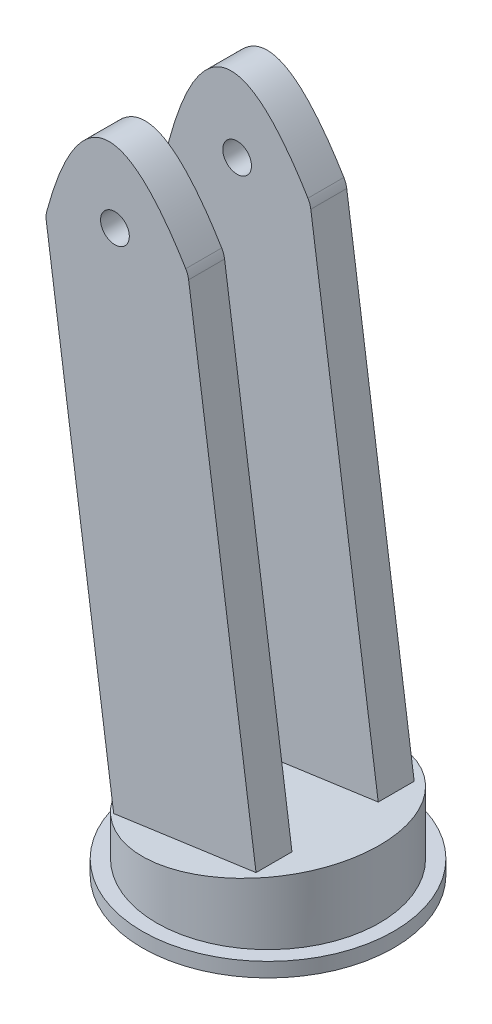
from build123d import *

# Parameters (mm, degrees)
CROQUIS2_R              = 17.5
SALIENTE_EXTRUIR1_DEPTH = 2
CROQUIS3_R              = 15.5
SALIENTE_EXTRUIR2_DEPTH = 10
CROQUIS6_W              = 20
CROQUIS6_H              = 5
SALIENTE_EXTRUIR4_DEPTH = 80
CROQUIS7_R              = 2
CORTAR_EXTRUIR4_DEPTH   = 97.577783797
REDONDEO1_R             = 3


with BuildPart() as part:
    # Croquis2 → Saliente-Extruir1 (new body)
    with BuildSketch(Plane(origin=(0, 0, 0), x_dir=(1, 0, 0), z_dir=(0, 1, 0))):
        with Locations(Location((0, 0, 0), (0, 0, 270))):
            Circle(CROQUIS2_R)
    extrude(amount=SALIENTE_EXTRUIR1_DEPTH)

    # Croquis3 → Saliente-Extruir2 (add)
    with BuildSketch(Plane(origin=(0, 2, 0), x_dir=(1, 0, 0), z_dir=(0, 1, 0))):
        with Locations(Location((0, 0, 0), (0, 0, 270))):
            Circle(CROQUIS3_R)
    extrude(amount=SALIENTE_EXTRUIR2_DEPTH)

    # Cortar con superficie2
    split(bisect_by=Plane(origin=(-1.264952602, 9.000605443, 0), x_dir=(0, 0, 1), z_dir=(-0.13917310096006574, 0.9902680687415703, 0)), keep=Keep.BOTTOM)

    # Croquis6 → Saliente-Extruir4 (add)
    with BuildSketch(Plane(origin=(-1.264952602, 9.000605443, 0), x_dir=(0.9902680687415704, 0.13917310096006577, 0), z_dir=(-0.13917310096006577, 0.9902680687415704, 0))):
        with Locations((0.7, -8.5)):
            Rectangle(CROQUIS6_W, CROQUIS6_H)
    saliente_extruir4 = extrude(amount=SALIENTE_EXTRUIR4_DEPTH)

    # Croquis7 → Cortar-Extruir4 (cut, through all)
    with BuildSketch(Plane.XY.offset(11)):
        with BuildLine():
            Line((-21.608293718, 86.927741104), (-19.938216506, 75.044524279))
            add(Edge.make_bspline(
                [(-19.938216506, 75.044524279), (-16.656953462, 87.623606273), (-11.705613295, 88.319472076)],
                knots=[0, 0, 0, 0.499999987, 0.499999987, 0.499999987], degree=2))
            Line((-11.705613295, 88.319472076), (-21.608293718, 86.927741104))
        make_face()
        with BuildLine():
            Line((-1.802932343, 89.711203123), (-11.705613295, 88.319472076))
            add(Edge.make_bspline(
                [(-11.705613295, 88.319472076), (-6.754272863, 89.015337917), (-0.132855132, 77.827986298)],
                knots=[0.499999987, 0.499999987, 0.499999987, 1, 1, 1], degree=2))
            Line((-0.132855132, 77.827986298), (-1.802932343, 89.711203123))
        make_face()
        with Locations((-10.300204683, 78.319472113)):
            Circle(CROQUIS7_R)
    cortar_extruir4 = extrude(amount=-CORTAR_EXTRUIR4_DEPTH, mode=Mode.SUBTRACT)

    # Simetría1: Saliente-Extruir4, Cortar-Extruir4 across plane
    add(saliente_extruir4.mirror(Plane.XY))
    add(cortar_extruir4.mirror(Plane.XY), mode=Mode.SUBTRACT)

    # Redondeo1
    redondeo1_edges = [part.edges().sort_by_distance(p)[0] for p in [
        (-0.132855132, 77.827986298, 8.5),
        (-19.938216506, 75.044524279, 8.5),
        (-0.132855132, 77.827986298, -8.5),
        (-19.938216506, 75.044524279, -8.5),
    ]]
    fillet(redondeo1_edges, radius=REDONDEO1_R)


solid = part.part
